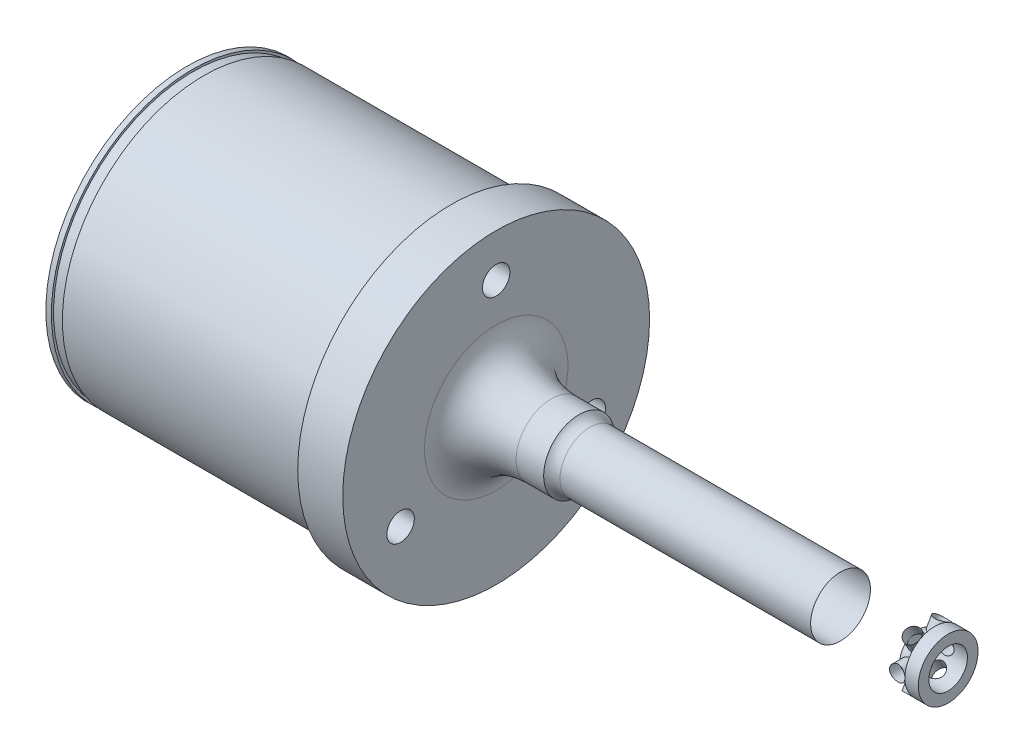
from build123d import *

# Parameters (mm, degrees)
SKETCH4_R              = 3.1623
DOWEL_PIN_HOLE_DEPTH   = 72.12
CIRPATTERN1_COUNT      = 3
SKETCH9_R              = 1.778
COTTER_PIN_HOLE_DEPTH  = 27.94
CIRPATTERN3_COUNT      = 3
SKETCH10_R             = 4.445
SHANK_TIP_RELIEF_DEPTH = 6.731
TULIP_PATTERN_DEPTH    = 66.04
CIRPATTERN2_COUNT      = 3
FILLET1_R              = 6.985
SKETCH8_R              = 30.607
TULIP_DEPTH_DEPTH      = 20.32


with BuildPart() as part:
    # Sketch1 → Base Revolve (revolve)
    with BuildSketch(Plane.XY):
        with BuildLine():
            Line((0, 16.51), (0, 35.306))
            Line((0, 35.306), (-10.3632, 35.306))
            Line((-10.3632, 35.306), (-10.3632, 32.766))
            Line((-10.3632, 32.766), (-71.12, 32.766))
            Line((-71.12, 32.766), (-71.12, 0))
            Line((-71.12, 0), (104.013, 0))
            Line((104.013, 0), (104.013, 6.8834))
            Line((104.013, 6.8834), (21.570750055, 6.8834))
            ThreePointArc((21.570750055, 6.8834), (20.165117635, 7.211503005), (19.05, 8.128))
            Line((19.05, 8.128), (12.7, 8.128))
            add(Edge.make_bspline(
                [(0, 16.51), (0, 8.128), (12.7, 8.128)],
                knots=[3.141592654, 3.141592654, 3.141592654, 4.71238898, 4.71238898, 4.71238898], degree=2, weights=[1, 0.707106781, 1]))
        make_face()
    revolve(axis=Axis((-132.525970605, 0, 0), (1, 0, 0)))

    # Sketch4 → Dowel Pin Hole (cut, through all)
    with BuildSketch(Plane(origin=(0, 0, 0), x_dir=(0, 0, -1), z_dir=(1, 0, 0))):
        with Locations((0, 25.4)):
            Circle(SKETCH4_R)
    dowel_pin_hole = extrude(amount=-DOWEL_PIN_HOLE_DEPTH, mode=Mode.SUBTRACT)

    # CirPattern1: Dowel Pin Hole ×3 about axis
    cirpattern1_axis = Axis((0, 0, 0), (1, 0, 0))
    for i in range(1, CIRPATTERN1_COUNT):
        add(dowel_pin_hole.rotate(cirpattern1_axis, i * 360 / CIRPATTERN1_COUNT), mode=Mode.SUBTRACT)

    # Sketch9 → Cotter Pin Hole (cut, symmetric)
    with BuildSketch(Plane.XY):
        with Locations((99.1616, 0)):
            Circle(SKETCH9_R)
    cotter_pin_hole = extrude(amount=COTTER_PIN_HOLE_DEPTH, both=True, mode=Mode.SUBTRACT)

    # CirPattern3: Cotter Pin Hole ×3 about axis
    cirpattern3_axis = Axis((116.645541128, 0, 0), (-1, 0, 0))
    for i in range(1, CIRPATTERN3_COUNT):
        add(cotter_pin_hole.rotate(cirpattern3_axis, i * 360 / CIRPATTERN3_COUNT), mode=Mode.SUBTRACT)

    # Sketch10 → Shank Tip Relief (cut)
    with BuildSketch(Plane(origin=(104.013, 0, 0), x_dir=(0, 0, -1), z_dir=(1, 0, 0))):
        Circle(SKETCH10_R)
    extrude(amount=-SHANK_TIP_RELIEF_DEPTH, mode=Mode.SUBTRACT)

    # Sketch5 → Tulip Pattern (cut)
    with BuildSketch(Plane.ZY.offset(71.12)):
        with BuildLine():
            ThreePointArc((-11.640374086, 14.022627835), (0, -18.2245), (11.640374086, 14.022627835))
            ThreePointArc((11.640374086, 14.022627835), (12.734443593, 21.104005871), (10.019410069, 27.73510653))
            ThreePointArc((10.019410069, 27.73510653), (0, 29.4894), (-10.019410069, 27.73510653))
            ThreePointArc((-10.019410069, 27.73510653), (-12.734443593, 21.104005871), (-11.640374086, 14.022627835))
        make_face()
        with BuildLine():
            ThreePointArc((-1.005691988, -19.303219627), (-6.343119482, -24.112031097), (-1.534308012, -29.449458591))
            ThreePointArc((-1.534308012, -29.449458591), (0, -29.4894), (1.534308012, -29.449458591))
            ThreePointArc((1.534308012, -29.449458591), (6.343119482, -24.112031097), (1.005691988, -19.303219627))
            ThreePointArc((1.005691988, -19.303219627), (0, -19.3294), (-1.005691988, -19.303219627))
        make_face()
    tulip_pattern = extrude(amount=-TULIP_PATTERN_DEPTH, mode=Mode.SUBTRACT)

    # CirPattern2: Tulip Pattern ×3 about axis
    cirpattern2_axis = Axis((0, 0, 0), (1, 0, 0))
    for i in range(1, CIRPATTERN2_COUNT):
        add(tulip_pattern.rotate(cirpattern2_axis, i * 360 / CIRPATTERN2_COUNT), mode=Mode.SUBTRACT)

    # Fillet1
    fillet1_edges = [part.edges().sort_by_distance(p)[0] for p in [
        (-38.1, -22.544616916, -19.009601797),
        (-38.1, -5.190489614, -29.029011866),
        (-38.1, -5.190489614, 29.029011866),
        (-38.1, -22.544616916, 19.009601797),
        (-38.1, 27.73510653, -10.019410069),
        (-38.1, 27.73510653, 10.019410069),
    ]]
    fillet(fillet1_edges, radius=FILLET1_R)

    # Sketch8 → Tulip Depth (cut)
    with BuildSketch(Plane.ZY.offset(71.12)):
        Circle(SKETCH8_R)
    extrude(amount=-TULIP_DEPTH_DEPTH, mode=Mode.SUBTRACT)

    # Sketch7 → Axle Relief (revolve, cut)
    with BuildSketch(Plane.XY):
        with BuildLine():
            Line((-5.08, 13.28592398), (-5.08, 0))
            Line((-5.08, 0), (-2.032, 0))
            ThreePointArc((-2.032, 0), (-2.803770837, 6.815535195), (-5.08, 13.28592398))
        make_face()
    revolve(axis=Axis((-5.08, 0, 0), (-1, 0, 0)), mode=Mode.SUBTRACT)

    # Sketch11 → Final Cut (revolve, cut)
    with BuildSketch(Plane.XY):
        with BuildLine():
            Line((-10.3632, 34.382877289), (-10.3632, 35.306))
            Line((-10.3632, 35.306), (-71.12, 35.306))
            Line((-71.12, 35.306), (-71.12, 32.51835))
            Line((-71.12, 32.51835), (-69.85, 32.51835))
            Line((-69.85, 32.51835), (-69.85, 32.01035))
            Line((-69.85, 32.01035), (-67.31, 32.01035))
            Line((-67.31, 32.01035), (-67.31, 32.51835))
            Line((-67.31, 32.51835), (-10.922, 32.51835))
            ThreePointArc((-10.922, 32.51835), (-9.948768341, 33.24267186), (-10.3632, 34.382877289))
        make_face()
    revolve(axis=Axis((116.645541128, 0, 0), (-1, 0, 0)), mode=Mode.SUBTRACT)


solid = part.part
